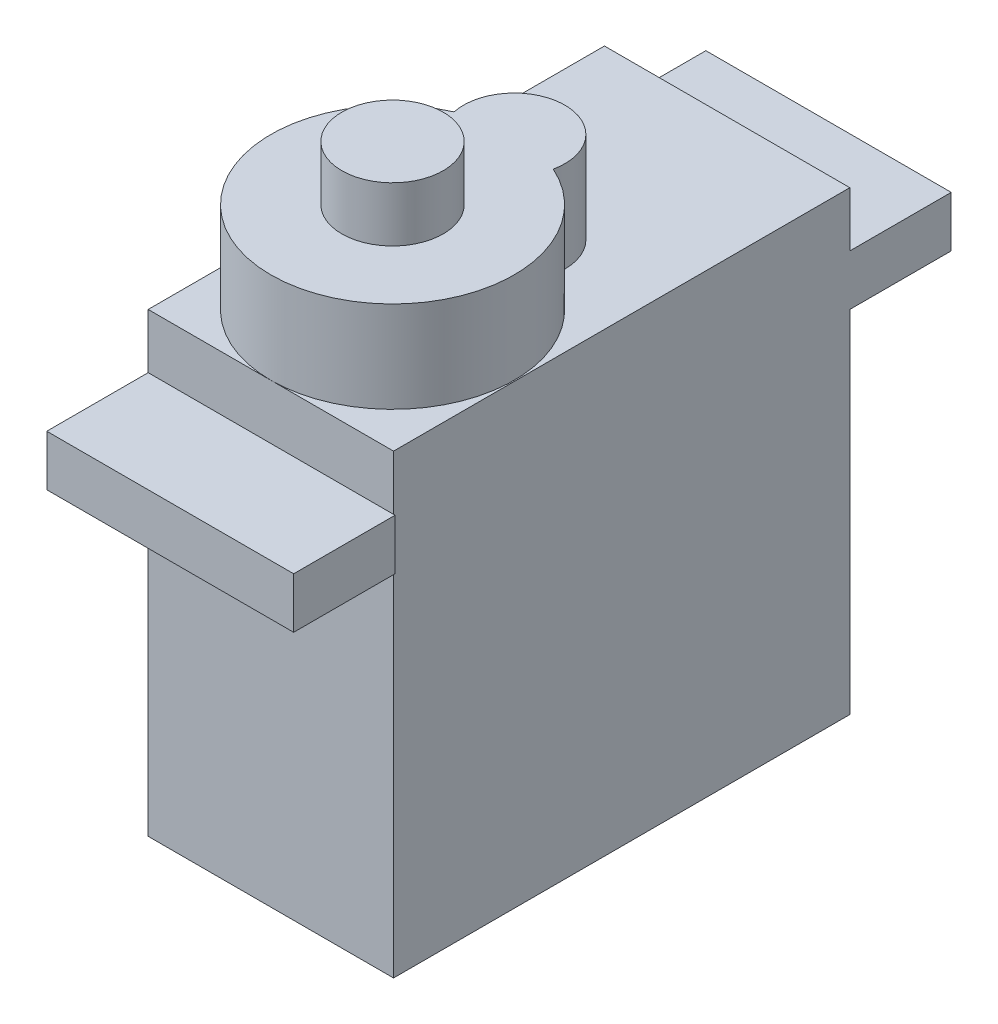
from build123d import *

# Parameters (mm, degrees)
SKETCH1_W           = 12.1
SKETCH1_H           = 22.5
BOSS_EXTRUDE1_DEPTH = 22.5
BOSS_EXTRUDE2_DEPTH = 4.5
SKETCH2_3_R         = 2.5
BOSS_EXTRUDE3_DEPTH = 7.2
SKETCH9_R           = 1.27
BOSS_EXTRUDE7_DEPTH = 3
SKETCH12_W          = 12.175
SKETCH12_H          = 5
SKETCH12_W_2        = 12.1
BOSS_EXTRUDE8_DEPTH = 19.8
SKETCH12_2_W        = 12.175
SKETCH12_2_H        = 5
SKETCH12_2_W_2      = 12.1
CUT_EXTRUDE1_DEPTH  = 17.3


with BuildPart() as part:
    # Sketch1 → Boss-Extrude1 (new body)
    with BuildSketch(Plane(origin=(0, 0, 0), x_dir=(1, 0, 0), z_dir=(0, 1, 0))):
        Rectangle(SKETCH1_W, SKETCH1_H)
    extrude(amount=BOSS_EXTRUDE1_DEPTH)

    # Sketch2 → Boss-Extrude2 (add)
    with BuildSketch(Plane(origin=(0, 22.5, 0), x_dir=(1, 0, 0), z_dir=(0, 1, 0))):
        with BuildLine():
            ThreePointArc((2.445144707, 0.229166667), (0, 3.25), (-2.445144707, 0.229166667))
            ThreePointArc((-2.445144707, 0.229166667), (0, -11.25), (2.445144707, 0.229166667))
        make_face()
    extrude(amount=BOSS_EXTRUDE2_DEPTH)

    # Sketch2_3 → Boss-Extrude3 (add)
    with BuildSketch(Plane(origin=(0, 22.5, 0), x_dir=(1, 0, 0), z_dir=(0, 1, 0))):
        with Locations((0, -5.25)):
            Circle(SKETCH2_3_R)
    extrude(amount=BOSS_EXTRUDE3_DEPTH)

    # Sketch9 → Boss-Extrude7 (add)
    with BuildSketch(Plane.XY.offset(11.25)):
        with Locations((0, 1.27)):
            Circle(SKETCH9_R)
        with Locations((-2.6, 1.27)):
            Circle(SKETCH9_R)
        with Locations((2.6, 1.27)):
            Circle(SKETCH9_R)
    extrude(amount=BOSS_EXTRUDE7_DEPTH)

    # Sketch12 → Boss-Extrude8 (add)
    with BuildSketch(Plane.XZ):
        with Locations((0.0375, 13.75)):
            Rectangle(SKETCH12_W, SKETCH12_H)
        with Locations((0, -13.75)):
            Rectangle(SKETCH12_W_2, SKETCH12_H)
    extrude(amount=-BOSS_EXTRUDE8_DEPTH)

    # Sketch12_2 → Cut-Extrude1 (cut)
    with BuildSketch(Plane.XZ):
        with Locations((0.0375, 13.75)):
            Rectangle(SKETCH12_2_W, SKETCH12_2_H)
        with Locations((0, -13.75)):
            Rectangle(SKETCH12_2_W_2, SKETCH12_2_H)
    extrude(amount=-CUT_EXTRUDE1_DEPTH, mode=Mode.SUBTRACT)


solid = part.part
